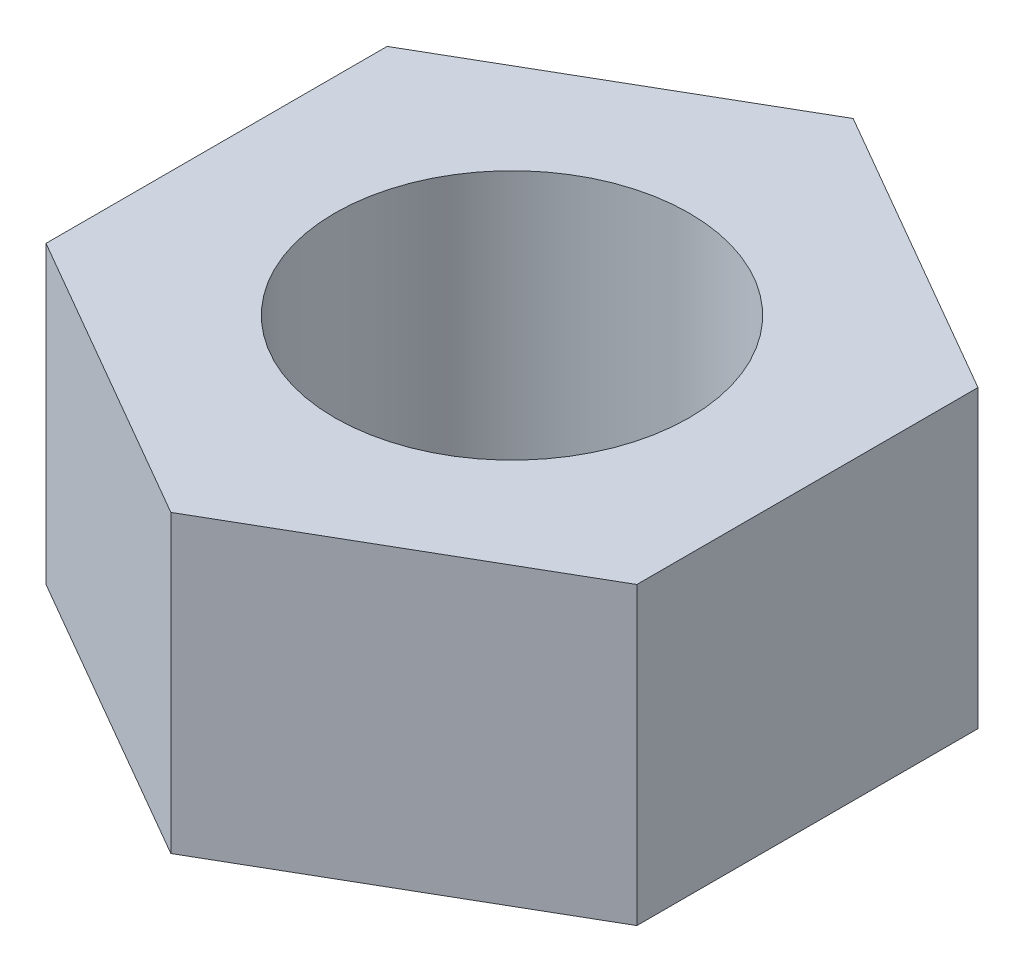
from build123d import *

# Parameters (mm, degrees)
SKETCH1_R           = 1.5
BOSS_EXTRUDE1_DEPTH = 2.5


with BuildPart() as part:
    # Sketch1 → Boss-Extrude1 (new body)
    with BuildSketch(Plane(origin=(0, 0, 0), x_dir=(1, 0, 0), z_dir=(0, 1, 0))):
        Polygon((0, 2.886751346), (-2.5, 1.443375673), (-2.5, -1.443375673), (0, -2.886751346), (2.5, -1.443375673), (2.5, 1.443375673), align=None)
        Circle(SKETCH1_R, mode=Mode.SUBTRACT)
    extrude(amount=BOSS_EXTRUDE1_DEPTH)


solid = part.part
